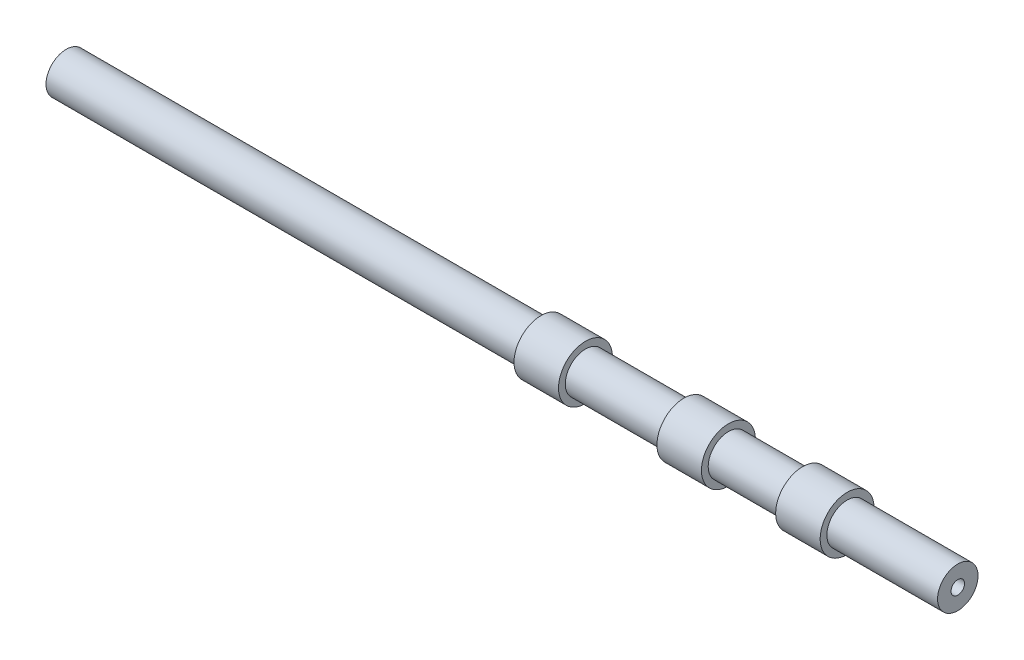
from build123d import *


with BuildPart() as part:
    # Sketch1 → Revolve-Thin1 (revolve)
    with BuildSketch(Plane.XY):
        Polygon((286.093493363, 15), (204.063493363, 15), (204.063493363, 20), (171.093493363, 20), (171.093493363, 15), (116.093493363, 15), (116.093493363, 20), (83.123493363, 20), (83.123493363, 15), (10.153493363, 15), (10.153493363, 20), (-22.816506637, 20), (-22.816506637, 15), (-143.276508184, 15), (-374.696506637, 15), (-374.696506637, 5), (-143.276508184, 5), (-12.816506637, 5), (-12.816506637, 10), (0.153493363, 10), (0.153493363, 5), (93.123493363, 5), (93.123493363, 10), (106.093493363, 10), (106.093493363, 5), (181.093493363, 5), (181.093493363, 10), (194.063493363, 10), (194.063493363, 5), (286.093493363, 5), align=None)
    revolve(axis=Axis((-141.82946491, 0, 0), (1, 0, 0)))


solid = part.part
